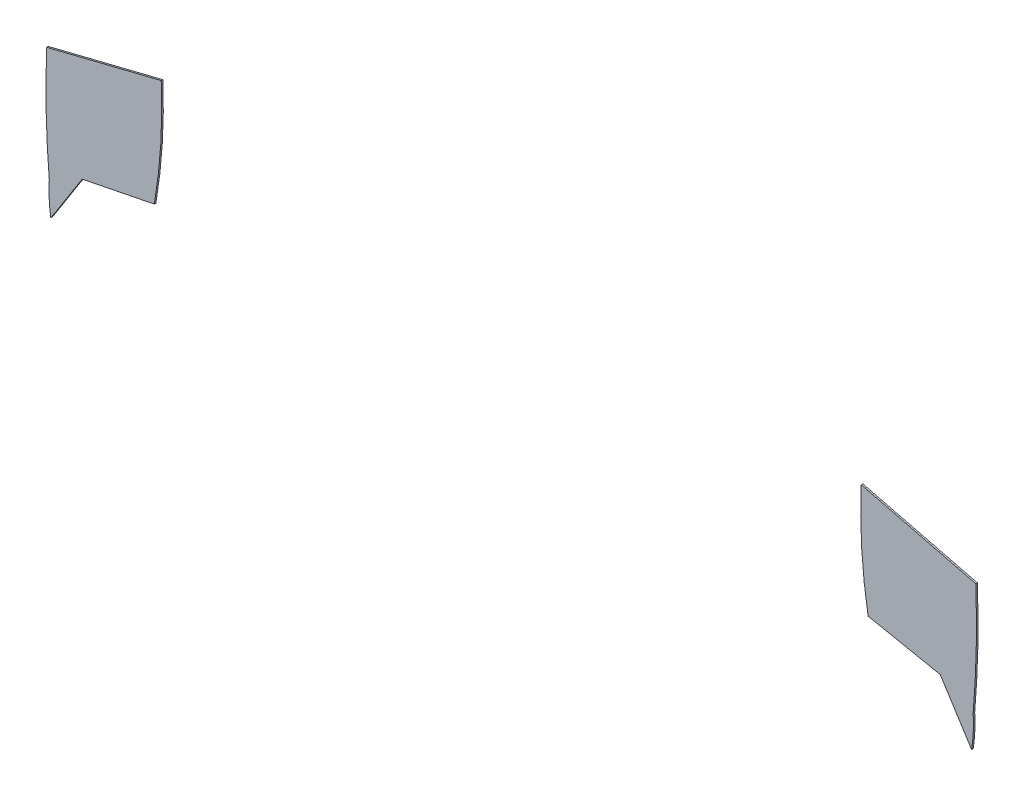
from build123d import *

# Parameters (mm, degrees)
SALIENTE_EXTRUIR1_DEPTH   = 0.1
SALIENTE_EXTRUIR1_2_DEPTH = 0.1


with BuildPart() as part:
    # Model → Saliente-Extruir1 (new body)
    with BuildSketch(Plane.XY):
        with BuildLine():
            Line((12.47051214, -1.34518661), (5.128289663, -3.167523437))
            ThreePointArc((5.128289663, -3.167523437), (5.096779394, -6.807884745), (5.293853737, -10.443044309))
            ThreePointArc((5.293853737, -10.443044309), (5.28344692, -11.479936915), (5.393218826, -12.511055097))
            Line((5.393218826, -12.511055097), (7.406998009, -9.347871018))
            Line((7.406998009, -9.347871018), (12.027985323, -8.423835121))
            ThreePointArc((12.027985323, -8.423835121), (12.440406197, -4.896461212), (12.47051214, -1.34518661))
        make_face()
    extrude(amount=SALIENTE_EXTRUIR1_DEPTH)


with BuildPart() as body_2:
    # Model → Saliente-Extruir1 2 (new body)
    with BuildSketch(Plane.XY):
        with BuildLine():
            Line((57.344273363, -1.346019767), (64.684709921, -3.168524547))
            ThreePointArc((64.684709921, -3.168524547), (64.730344073, -5.511351893), (64.680968663, -7.854103378))
            ThreePointArc((64.680968663, -7.854103378), (64.613474445, -9.139037986), (64.517391056, -10.422151543))
            ThreePointArc((64.517391056, -10.422151543), (64.529583716, -11.469964899), (64.41946664, -12.512047295))
            Line((64.41946664, -12.512047295), (62.4057938, -9.348795516))
            Line((62.4057938, -9.348795516), (57.784837554, -8.424604267))
            ThreePointArc((57.784837554, -8.424604267), (57.374583379, -4.897135694), (57.344273363, -1.346019767))
        make_face()
    extrude(amount=SALIENTE_EXTRUIR1_2_DEPTH)


solid = Compound([part.part, body_2.part])
